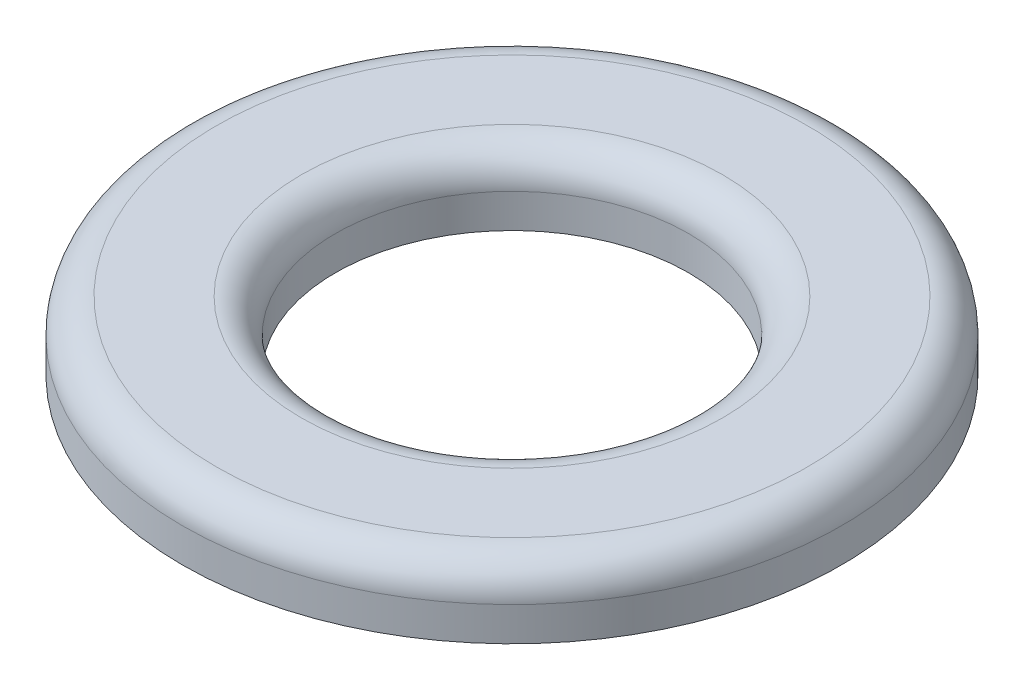
from build123d import *

# Parameters (mm, degrees)
SKETCH_1_R      = 4.85
SKETCH_1_R_2    = 2.6
EXTRUDE_1_DEPTH = 1
FILLET_1_R      = 0.5


with BuildPart() as part:
    # 草图1 → 凸台-拉伸1 (new body)
    with BuildSketch(Plane(origin=(0, 0, 0), x_dir=(1, 0, 0), z_dir=(0, 1, 0))):
        Circle(SKETCH_1_R)
        Circle(SKETCH_1_R_2, mode=Mode.SUBTRACT)
    extrude(amount=EXTRUDE_1_DEPTH)

    # 圆角1
    fillet_1_edges = [part.edges().sort_by_distance(p)[0] for p in [
        (-4.85, 1, 0),
        (-2.6, 1, 0),
    ]]
    fillet(fillet_1_edges, radius=FILLET_1_R)


solid = part.part
